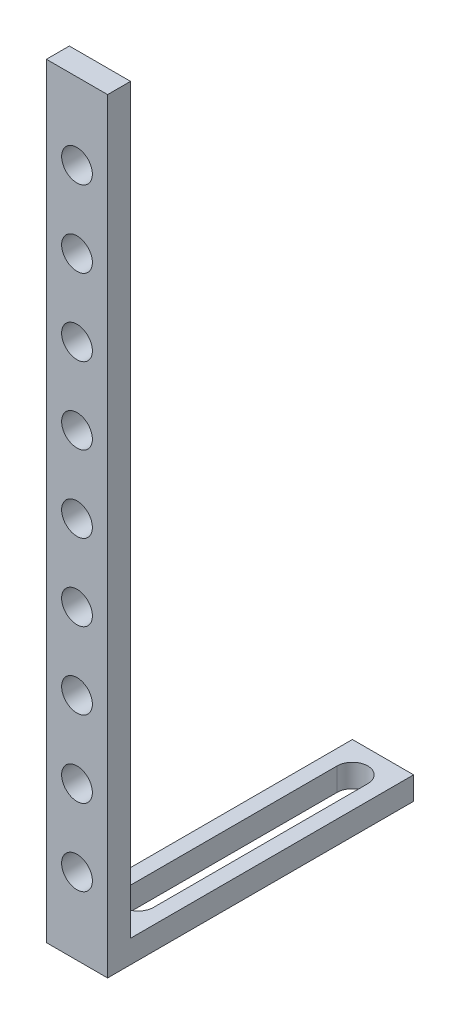
from build123d import *

# Parameters (mm, degrees)
EXTRUDE_1_DEPTH     = 40
SKETCH_2_R          = 10.05
CUT_EXTRUDE_1_DEPTH = 201
CUT_EXTRUDE_2_REACH = 502


with BuildPart() as part:
    # Эскиз1 → Бобышка-Вытянуть1 (new body)
    with BuildSketch(Plane(origin=(0, 0, 0), x_dir=(0, 0, -1), z_dir=(1, 0, 0))):
        Polygon((0, 0), (0, 500), (15, 500), (15, 15), (200, 15), (200, 0), align=None)
    extrude(amount=EXTRUDE_1_DEPTH)

    # Эскиз2 → Вырез-Вытянуть1 (cut, through all)
    with BuildSketch(Plane.XY):
        with Locations((20, 50)):
            Circle(SKETCH_2_R)
        with Locations((20, 100)):
            Circle(SKETCH_2_R)
        with Locations((20, 150)):
            Circle(SKETCH_2_R)
        with Locations((20, 200)):
            Circle(SKETCH_2_R)
        with Locations((20, 250)):
            Circle(SKETCH_2_R)
        with Locations((20, 300)):
            Circle(SKETCH_2_R)
        with Locations((20, 350)):
            Circle(SKETCH_2_R)
        with Locations((20, 400)):
            Circle(SKETCH_2_R)
        with Locations((20, 450)):
            Circle(SKETCH_2_R)
    extrude(amount=-CUT_EXTRUDE_1_DEPTH, mode=Mode.SUBTRACT)

    # Эскиз3 → Вырез-Вытянуть2 (cut, up to next)
    with BuildSketch(Plane.XZ, mode=Mode.PRIVATE) as cut_extrude_2_sk1:
        with BuildLine():
            Line((9.95, -40), (9.95, -180))
            ThreePointArc((9.95, -180), (20, -190.05), (30.05, -180))
            Line((30.05, -180), (30.05, -40))
            ThreePointArc((30.05, -40), (20, -29.95), (9.95, -40))
        make_face()
    cut_extrude_2_tool1 = extrude(cut_extrude_2_sk1.sketch, amount=-CUT_EXTRUDE_2_REACH, mode=Mode.PRIVATE) & part.part
    add(cut_extrude_2_tool1.solids().sort_by_distance((20, 0, -110))[0], mode=Mode.SUBTRACT)


solid = part.part
